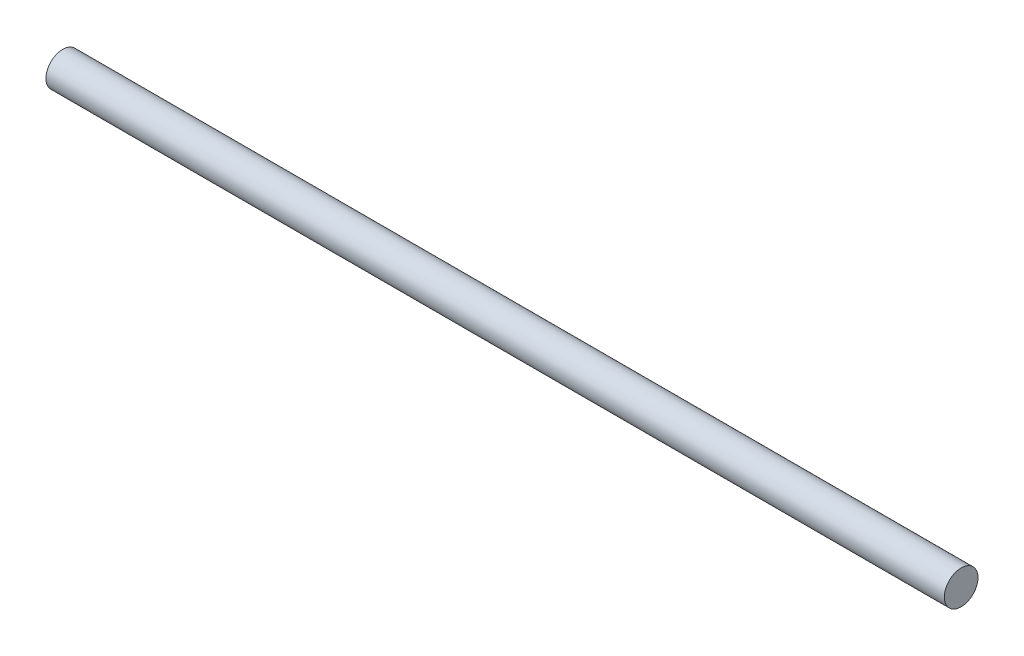
from build123d import *

# Parameters (mm, degrees)
SWEEP2_PROFILE_R = 0.1905


with BuildPart() as part:
    # Sweep2: sweep along a path in Sketch6
    with BuildLine(Plane.XY) as sweep2_path:
        Line((0, 0), (10.16, 0))
    # Sweep2 profile (on start of the path) → Sweep2 (sweep)
    with BuildSketch(Plane(origin=(0, 0, 0), x_dir=(0, 0, 1), z_dir=(1, 0, 0))):
        Circle(SWEEP2_PROFILE_R)
    sweep(path=sweep2_path.line)


solid = part.part
